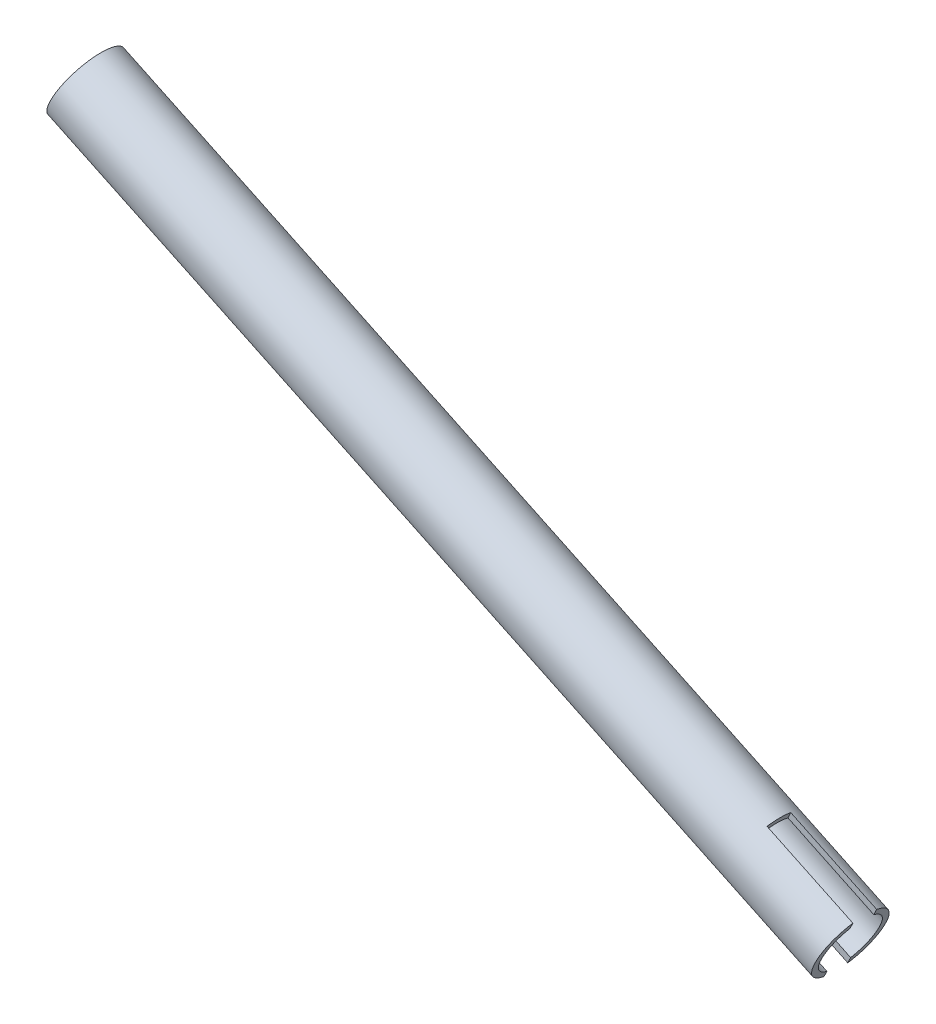
from build123d import *

# Parameters (mm, degrees)
CUT_EXTRUDE1_START = -25.4
SKETCH2_W          = 6.35
SKETCH2_H          = 19.05
CUT_EXTRUDE1_DEPTH = 25.4


with BuildPart() as part:
    # Sketch1 → Revolve1 (revolve)
    with BuildSketch(Plane.XY):
        Polygon((520.646295907, -1547.882062127), (519.936476988, -1549.372685521), (315.784745775, -1452.157814294), (316.494564694, -1450.6671909), align=None)
    revolve(axis=Axis((319.879854926, -1443.558063946, 0), (0.902860929, -0.429932719, 0)))

    # Sketch2 → Cut-Extrude1 (cut)
    with BuildSketch(Plane(origin=(1025.2494541, -488.212826138, 0), x_dir=(0, 0, -1), z_dir=(0.902860929, -0.429932719, 0)).offset(CUT_EXTRUDE1_START)):
        with Locations((0, -1165.805358667)):
            Rectangle(SKETCH2_W, SKETCH2_H)
    extrude(amount=CUT_EXTRUDE1_DEPTH, mode=Mode.SUBTRACT)


solid = part.part
